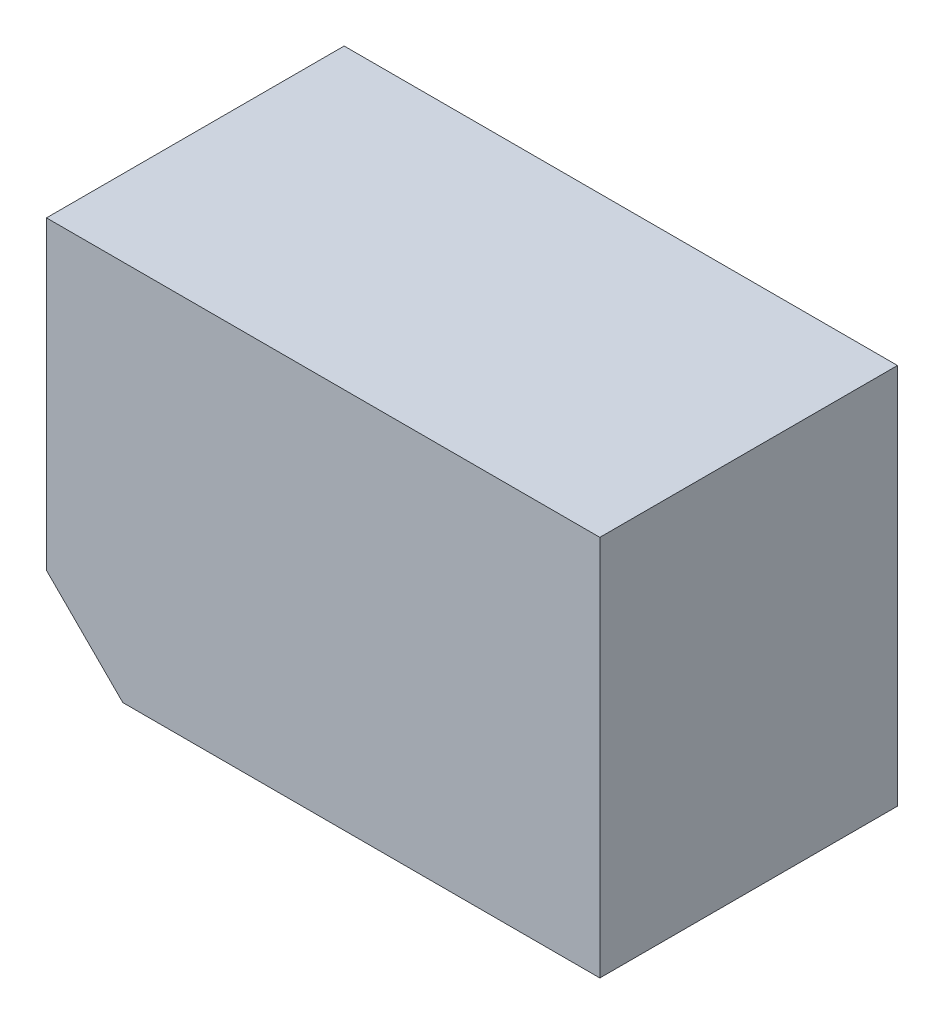
from build123d import *

# Parameters (mm, degrees)
BOSS_EXTRUDE1_DEPTH = 78


with BuildPart() as part:
    # Sketch1 → Boss-Extrude1 (new body)
    with BuildSketch(Plane.XY):
        Polygon((-125, -100), (-145, -80), (-145, 0), (0, 0), (0, -100), align=None)
    extrude(amount=BOSS_EXTRUDE1_DEPTH)


solid = part.part
